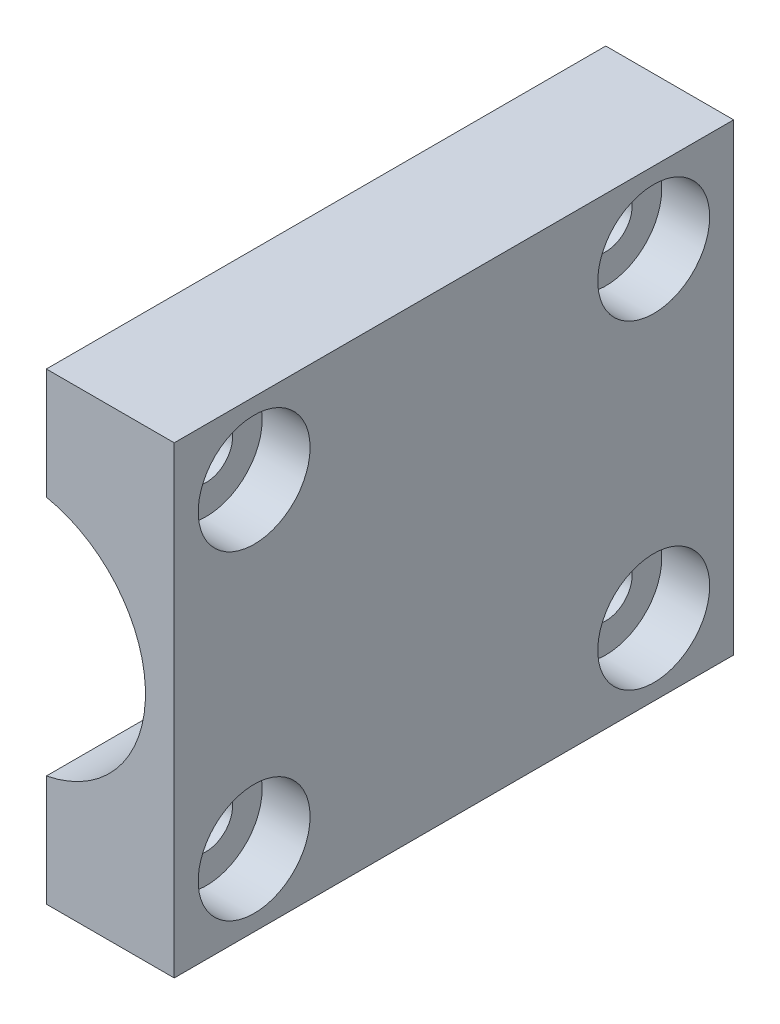
from build123d import *

# Parameters (mm, degrees)
ESBO_O2_R                  = 7.7
ESBO_O2_W                  = 7
ESBO_O2_H                  = 10
RESSALTO_EXTRUS_O1_DEPTH   = 35
ESBO_O3_R                  = 1.65
CORTE_EXTRUS_O1_DEPTH      = 20
ESBO_O4_R                  = 1.6
CORTE_EXTRUS_O2_DEPTH      = 18.5
CORTE_EXTRUS_O2_DEPTH_BACK = 48.5
CORTE_EXTRUS_O4_START      = -8
ESBO_O8_W                  = 35
ESBO_O8_H                  = 65
CORTE_EXTRUS_O4_DEPTH      = 39
ESBO_O11_W                 = 8
ESBO_O11_H                 = 18
CORTE_EXTRUS_O6_DEPTH      = 1
CORTE_EXTRUS_O6_DEPTH_BACK = 36
ESBO_O12_R                 = 3.5
CORTE_EXTRUS_O7_DEPTH      = 3


with BuildPart() as part:
    # Esboço2 → Ressalto-extrusão1 (new body)
    with BuildSketch(Plane.XY):
        Polygon((-9.5, 15), (-9.5, 32.5), (9.5, 32.5), (9.5, -32.5), (-9.5, -32.5), (-9.5, -15), (-25, -15), (-25, -12), (-9, -12), (-9, -2), (-25, -2), (-36.5, -2), (-36.5, 2), (-20.5, 2), (-20.5, 12), (-36.5, 12), (-36.5, 15), align=None)
        Circle(ESBO_O2_R, mode=Mode.SUBTRACT)
        with Locations((-12.5, 7)):
            Rectangle(ESBO_O2_W, ESBO_O2_H, mode=Mode.SUBTRACT)
    extrude(amount=RESSALTO_EXTRUS_O1_DEPTH)

    # Esboço3 → Corte-extrusão1 (cut, through all)
    with BuildSketch(Plane.ZY.offset(9.5)):
        with Locations((17.5, 18)):
            Circle(ESBO_O3_R)
        with Locations((17.5, -18)):
            Circle(ESBO_O3_R)
        with Locations((5, 10)):
            Circle(ESBO_O3_R)
        with Locations((30, 10)):
            Circle(ESBO_O3_R)
        with Locations((5, -10)):
            Circle(ESBO_O3_R)
        with Locations((30, -10)):
            Circle(ESBO_O3_R)
        Polygon((35, 30.736730193), (25, 32.5), (35, 32.5), align=None)
        Polygon((24.739796996, 20.169435313), (30.057758862, 19.231735154), (29.536814329, 16.277311895), (24.218852463, 17.215012054), align=None)
        with BuildLine():
            Line((21.321510517, 23.818451283), (42.639721186, 20.059475562))
            Line((42.639721186, 20.059475562), (42.813369364, 21.044283315))
            Line((42.813369364, 21.044283315), (21.495158694, 24.803259036))
            ThreePointArc((21.495158694, 24.803259036), (13.560768988, 25.694592711), (21.321510517, 23.818451283))
        make_face()
        with BuildLine():
            Line((42.639721186, -20.059475562), (42.813369364, -21.044283315))
            Line((42.813369364, -21.044283315), (21.495158694, -24.803259036))
            ThreePointArc((21.495158694, -24.803259036), (13.560768988, -25.694592711), (21.321510517, -23.818451283))
            Line((21.321510517, -23.818451283), (42.639721186, -20.059475562))
        make_face()
        Polygon((30.057758862, -19.231735154), (29.536814329, -16.277311895), (24.218852463, -17.215012054), (24.739796996, -20.169435313), align=None)
        Polygon((0, 30.736730193), (10, 32.5), (0, 32.5), align=None)
        Polygon((35, -32.5), (25, -32.5), (35, -30.736730193), align=None)
        Polygon((0, -32.5), (10, -32.5), (0, -30.736730193), align=None)
    extrude(amount=-CORTE_EXTRUS_O1_DEPTH, mode=Mode.SUBTRACT)

    # Esboço4 → Corte-extrusão2 (cut, two sides)
    with BuildSketch(Plane(origin=(0, 15, 0), x_dir=(1, 0, 0), z_dir=(0, 1, 0))) as corte_extrus_o2_sk:
        with Locations((-32, -11.5)):
            Circle(ESBO_O4_R)
        with Locations((-19, -23.5)):
            Circle(ESBO_O4_R)
    extrude(amount=CORTE_EXTRUS_O2_DEPTH, mode=Mode.SUBTRACT)
    extrude(corte_extrus_o2_sk.sketch, amount=-CORTE_EXTRUS_O2_DEPTH_BACK, mode=Mode.SUBTRACT)

    # Esboço8 → Corte-extrusão4 (cut, through all)
    with BuildSketch(Plane(origin=(9.5, 0, 0), x_dir=(0, 0, -1), z_dir=(1, 0, 0)).offset(CORTE_EXTRUS_O4_START)):
        with Locations((-17.5, 0)):
            Rectangle(ESBO_O8_W, ESBO_O8_H)
    extrude(amount=-CORTE_EXTRUS_O4_DEPTH, mode=Mode.SUBTRACT)

    # Esboço11 → Corte-extrusão6 (cut, two sides)
    with BuildSketch(Plane(origin=(0, 0, 0), x_dir=(-1, 0, 0), z_dir=(0, 0, -1))) as corte_extrus_o6_sk:
        with Locations((-5.5, 23.5)):
            Rectangle(ESBO_O11_W, ESBO_O11_H)
        with Locations((-5.5, -23.5)):
            Rectangle(ESBO_O11_W, ESBO_O11_H)
    extrude(amount=CORTE_EXTRUS_O6_DEPTH, mode=Mode.SUBTRACT)
    extrude(corte_extrus_o6_sk.sketch, amount=-CORTE_EXTRUS_O6_DEPTH_BACK, mode=Mode.SUBTRACT)

    # Esboço12 → Corte-extrusão7 (cut)
    with BuildSketch(Plane(origin=(9.5, 0, 0), x_dir=(0, 0, -1), z_dir=(1, 0, 0))):
        with Locations((-30, 10)):
            Circle(ESBO_O12_R)
        with Locations((-5, 10)):
            Circle(ESBO_O12_R)
        with Locations((-5, -10)):
            Circle(ESBO_O12_R)
        with Locations((-30, -10)):
            Circle(ESBO_O12_R)
    extrude(amount=-CORTE_EXTRUS_O7_DEPTH, mode=Mode.SUBTRACT)


solid = part.part
